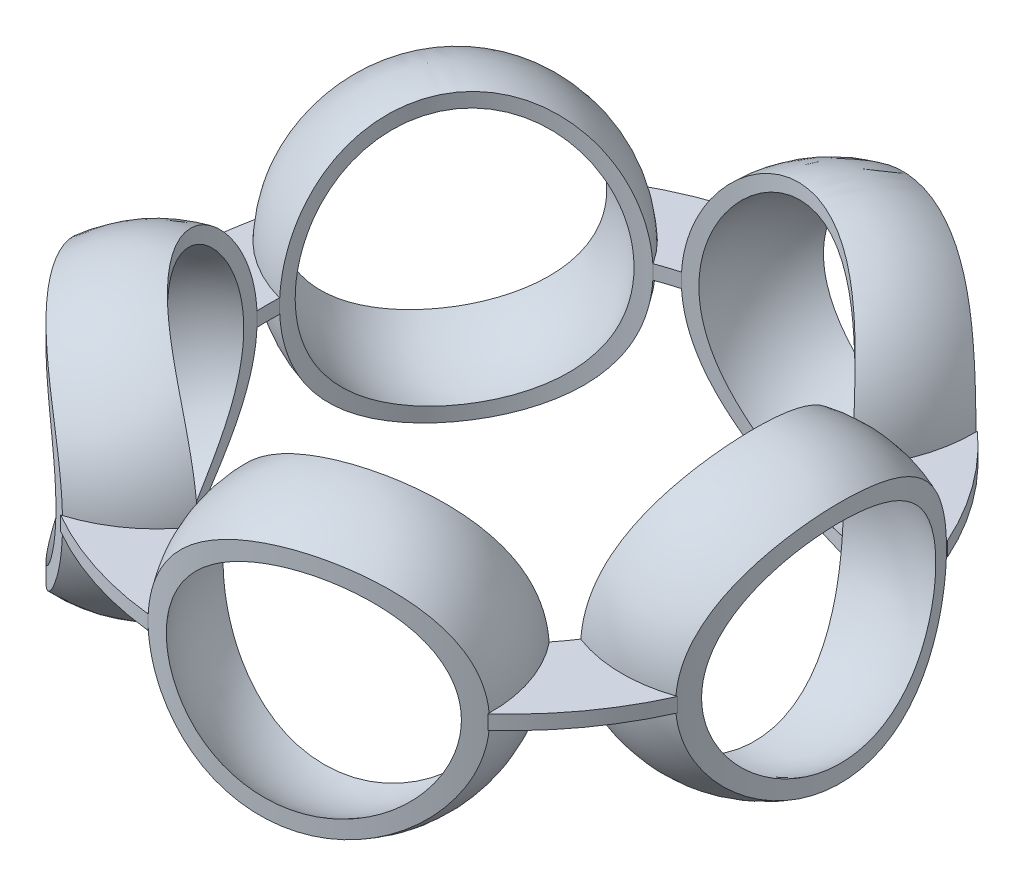
from build123d import *

# Parameters (mm, degrees)
CIRPATTERN2_COUNT       = 5
CUT_EXTRUDE1_DEPTH      = 10
CUT_EXTRUDE1_DEPTH_BACK = 5
SKETCH2_R               = 6
SKETCH2_R_2             = 4.6
CUT_EXTRUDE2_DEPTH      = 5
CUT_EXTRUDE2_DEPTH_BACK = 5
SKETCH3_R               = 3.4
BOSS_EXTRUDE1_DEPTH     = 0.1
BOSS_EXTRUDE1_2_DEPTH   = 0.1
BOSS_EXTRUDE1_3_DEPTH   = 0.1
BOSS_EXTRUDE1_4_DEPTH   = 0.1
BOSS_EXTRUDE1_5_DEPTH   = 0.1


with BuildPart() as part:
    # Sketch1 → Revolve1 (revolve)
    with BuildSketch(Plane(origin=(0, 0, 0), x_dir=(1, 0, 0), z_dir=(0, 1, 0))):
        with BuildLine():
            Line((3.55, 2), (3.55, 1.8))
            ThreePointArc((3.55, 1.8), (5.35, 0), (3.55, -1.8))
            Line((3.55, -1.8), (3.55, -2))
            ThreePointArc((3.55, -2), (5.55, 0), (3.55, 2))
        make_face()
    revolve(axis=Axis((3.55, 0, -2), (0, 0, 1)))


with BuildPart() as cirpattern2_1:
    # CirPattern2: pattern copy
    add(part.part.rotate(Axis((0, 50, 0), (0, -1, 0)), 1 * 360 / CIRPATTERN2_COUNT))


with BuildPart() as cirpattern2_2:
    # CirPattern2: pattern copy
    add(part.part.rotate(Axis((0, 50, 0), (0, -1, 0)), 2 * 360 / CIRPATTERN2_COUNT))


with BuildPart() as cirpattern2_3:
    # CirPattern2: pattern copy
    add(part.part.rotate(Axis((0, 50, 0), (0, -1, 0)), 3 * 360 / CIRPATTERN2_COUNT))


with BuildPart() as cirpattern2_4:
    # CirPattern2: pattern copy
    add(part.part.rotate(Axis((0, 50, 0), (0, -1, 0)), 4 * 360 / CIRPATTERN2_COUNT))


with BuildPart() as cut_extrude1_tool:
    # Sketch2 → Cut-Extrude1 (new, two sides: drawn at the far end of the back side and taken through both)
    with BuildSketch(Plane(origin=(0, 0, 0), x_dir=(1, 0, 0), z_dir=(0, 1, 0)).offset(-CUT_EXTRUDE1_DEPTH_BACK)):
        Circle(SKETCH2_R)
        Circle(SKETCH2_R_2, mode=Mode.SUBTRACT)
    extrude(amount=CUT_EXTRUDE1_DEPTH + CUT_EXTRUDE1_DEPTH_BACK)


with BuildPart() as part_1:
    add(part.part)

    # Cut-Extrude1: cut by cut_extrude1_tool
    add(cut_extrude1_tool.part, mode=Mode.SUBTRACT)


with BuildPart() as cirpattern2_1_1:
    add(cirpattern2_1.part)

    # Cut-Extrude1: cut by cut_extrude1_tool
    add(cut_extrude1_tool.part, mode=Mode.SUBTRACT)


with BuildPart() as cirpattern2_2_1:
    add(cirpattern2_2.part)

    # Cut-Extrude1: cut by cut_extrude1_tool
    add(cut_extrude1_tool.part, mode=Mode.SUBTRACT)


with BuildPart() as cirpattern2_3_1:
    add(cirpattern2_3.part)

    # Cut-Extrude1: cut by cut_extrude1_tool
    add(cut_extrude1_tool.part, mode=Mode.SUBTRACT)


with BuildPart() as cirpattern2_4_1:
    add(cirpattern2_4.part)

    # Cut-Extrude1: cut by cut_extrude1_tool
    add(cut_extrude1_tool.part, mode=Mode.SUBTRACT)


with BuildPart() as cut_extrude2_tool:
    # Sketch3 → Cut-Extrude2 (new, two sides: drawn at the far end of the back side and taken through both)
    with BuildSketch(Plane(origin=(0, 0, 0), x_dir=(1, 0, 0), z_dir=(0, 1, 0)).offset(-CUT_EXTRUDE2_DEPTH_BACK)):
        Circle(SKETCH3_R)
    extrude(amount=CUT_EXTRUDE2_DEPTH + CUT_EXTRUDE2_DEPTH_BACK)


with BuildPart() as part_2:
    add(part_1.part)

    # Cut-Extrude2: cut by cut_extrude2_tool
    add(cut_extrude2_tool.part, mode=Mode.SUBTRACT)


with BuildPart() as cirpattern2_1_2:
    add(cirpattern2_1_1.part)

    # Cut-Extrude2: cut by cut_extrude2_tool
    add(cut_extrude2_tool.part, mode=Mode.SUBTRACT)


with BuildPart() as cirpattern2_2_2:
    add(cirpattern2_2_1.part)

    # Cut-Extrude2: cut by cut_extrude2_tool
    add(cut_extrude2_tool.part, mode=Mode.SUBTRACT)


with BuildPart() as cirpattern2_3_2:
    add(cirpattern2_3_1.part)

    # Cut-Extrude2: cut by cut_extrude2_tool
    add(cut_extrude2_tool.part, mode=Mode.SUBTRACT)


with BuildPart() as cirpattern2_4_2:
    add(cirpattern2_4_1.part)

    # Cut-Extrude2: cut by cut_extrude2_tool
    add(cut_extrude2_tool.part, mode=Mode.SUBTRACT)


with BuildPart() as body_6:
    # Sketch4 → Boss-Extrude1 (new, symmetric)
    with BuildSketch(Plane(origin=(0, 0, 0), x_dir=(1, 0, 0), z_dir=(0, 1, 0))):
        with BuildLine():
            ThreePointArc((-0.493082326, 4.58934805), (-1.42634846, 4.389849175), (-2.29863912, 4.002687085))
            ThreePointArc((-2.29863912, 4.002687085), (-1.675926874, 3.689567577), (-1.19848326, 3.181766471))
            ThreePointArc((-1.19848326, 3.181766471), (-1.050657781, 3.233592155), (-0.900602084, 3.278553932))
            ThreePointArc((-0.900602084, 3.278553932), (-0.812820087, 3.970007972), (-0.493082326, 4.58934805))
        make_face()
    extrude(amount=BOSS_EXTRUDE1_DEPTH, both=True)


with BuildPart() as body_7:
    # Sketch4 → Boss-Extrude1 2 (new, symmetric)
    with BuildSketch(Plane(origin=(0, 0, 0), x_dir=(1, 0, 0), z_dir=(0, 1, 0))):
        with BuildLine():
            ThreePointArc((-4.517100187, 0.949237381), (-4.026877172, 0.453762091), (-3.39639143, 0.156605402))
            ThreePointArc((-3.39639143, 0.156605402), (-3.4, 0), (-3.39639143, -0.156605402))
            ThreePointArc((-3.39639143, -0.156605402), (-4.026877172, -0.453762091), (-4.517100187, -0.949237381))
            ThreePointArc((-4.517100187, -0.949237381), (-4.615760577, 0), (-4.517100187, 0.949237381))
        make_face()
    extrude(amount=BOSS_EXTRUDE1_2_DEPTH, both=True)


with BuildPart() as body_8:
    # Sketch4 → Boss-Extrude1 3 (new, symmetric)
    with BuildSketch(Plane(origin=(0, 0, 0), x_dir=(1, 0, 0), z_dir=(0, 1, 0))):
        with BuildLine():
            ThreePointArc((-2.29863912, -4.002687085), (-1.675926874, -3.689567577), (-1.19848326, -3.181766471))
            ThreePointArc((-1.19848326, -3.181766471), (-1.050657781, -3.233592155), (-0.900602084, -3.278553932))
            ThreePointArc((-0.900602084, -3.278553932), (-0.812820087, -3.970007972), (-0.493082326, -4.58934805))
            ThreePointArc((-0.493082326, -4.58934805), (-1.42634846, -4.389849175), (-2.29863912, -4.002687085))
        make_face()
    extrude(amount=BOSS_EXTRUDE1_3_DEPTH, both=True)


with BuildPart() as body_9:
    # Sketch4 → Boss-Extrude1 4 (new, symmetric)
    with BuildSketch(Plane(origin=(0, 0, 0), x_dir=(1, 0, 0), z_dir=(0, 1, 0))):
        with BuildLine():
            ThreePointArc((3.096463083, -3.423034046), (2.991097401, -2.734040257), (2.655688041, -2.123045225))
            ThreePointArc((2.655688041, -2.123045225), (2.750657781, -1.998469858), (2.839788732, -1.869652362))
            ThreePointArc((2.839788732, -1.869652362), (3.524526731, -1.999837772), (4.21235855, -1.8871357))
            ThreePointArc((4.21235855, -1.8871357), (3.734228749, -2.713075995), (3.096463083, -3.423034046))
        make_face()
    extrude(amount=BOSS_EXTRUDE1_4_DEPTH, both=True)


with BuildPart() as body_10:
    # Sketch4 → Boss-Extrude1 5 (new, symmetric)
    with BuildSketch(Plane(origin=(0, 0, 0), x_dir=(1, 0, 0), z_dir=(0, 1, 0))):
        with BuildLine():
            ThreePointArc((4.21235855, 1.8871357), (3.524526731, 1.999837772), (2.839788732, 1.869652362))
            ThreePointArc((2.839788732, 1.869652362), (2.750657781, 1.998469858), (2.655688041, 2.123045225))
            ThreePointArc((2.655688041, 2.123045225), (2.991097401, 2.734040257), (3.096463083, 3.423034046))
            ThreePointArc((3.096463083, 3.423034046), (3.734228749, 2.713075995), (4.21235855, 1.8871357))
        make_face()
    extrude(amount=BOSS_EXTRUDE1_5_DEPTH, both=True)


solid = Compound([part_2.part, cirpattern2_1_2.part, cirpattern2_2_2.part, cirpattern2_3_2.part, cirpattern2_4_2.part, body_6.part, body_7.part, body_8.part, body_9.part, body_10.part])
